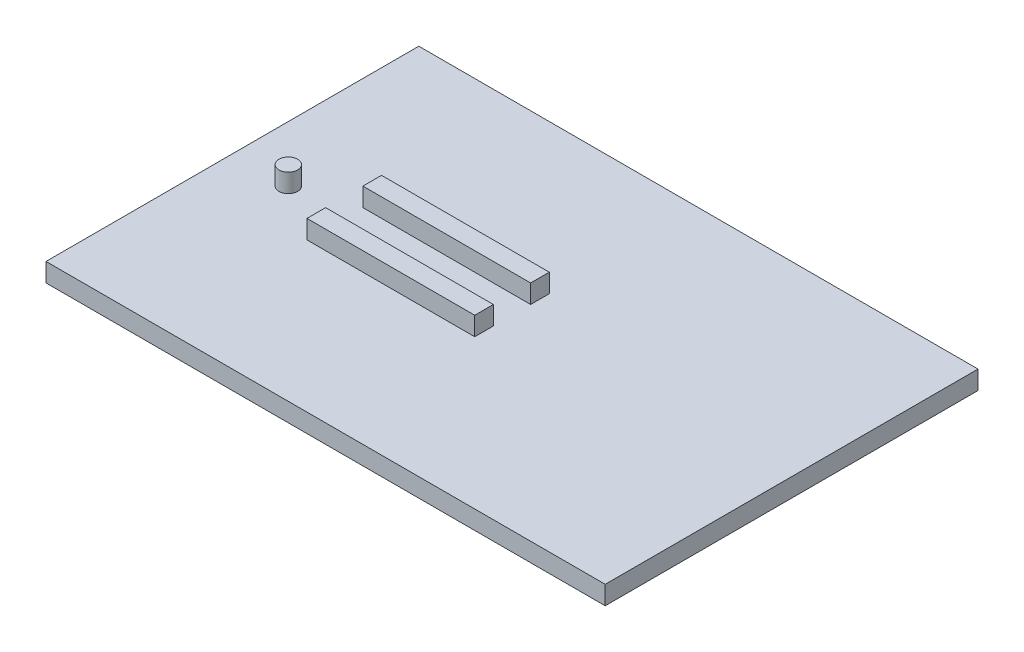
from build123d import *

# Parameters (mm, degrees)
SKETCH1_W           = 300
SKETCH1_H           = 200
BOSS_EXTRUDE1_DEPTH = 10
SKETCH2_R           = 5
SKETCH2_W           = 90
SKETCH2_H           = 10
BOSS_EXTRUDE2_DEPTH = 10


with BuildPart() as part:
    # Sketch1 → Boss-Extrude1 (new body)
    with BuildSketch(Plane(origin=(0, 0, 0), x_dir=(1, 0, 0), z_dir=(0, 1, 0))):
        with Locations((150, 100)):
            Rectangle(SKETCH1_W, SKETCH1_H)
    extrude(amount=BOSS_EXTRUDE1_DEPTH)

    # Sketch2 → Boss-Extrude2 (add)
    with BuildSketch(Plane(origin=(0, 10, 0), x_dir=(1, 0, 0), z_dir=(0, 1, 0))):
        with Locations((30, 100)):
            Circle(SKETCH2_R)
        with Locations((105, 115)):
            Rectangle(SKETCH2_W, SKETCH2_H)
        with Locations((105, 85)):
            Rectangle(SKETCH2_W, SKETCH2_H)
    extrude(amount=BOSS_EXTRUDE2_DEPTH)


solid = part.part
